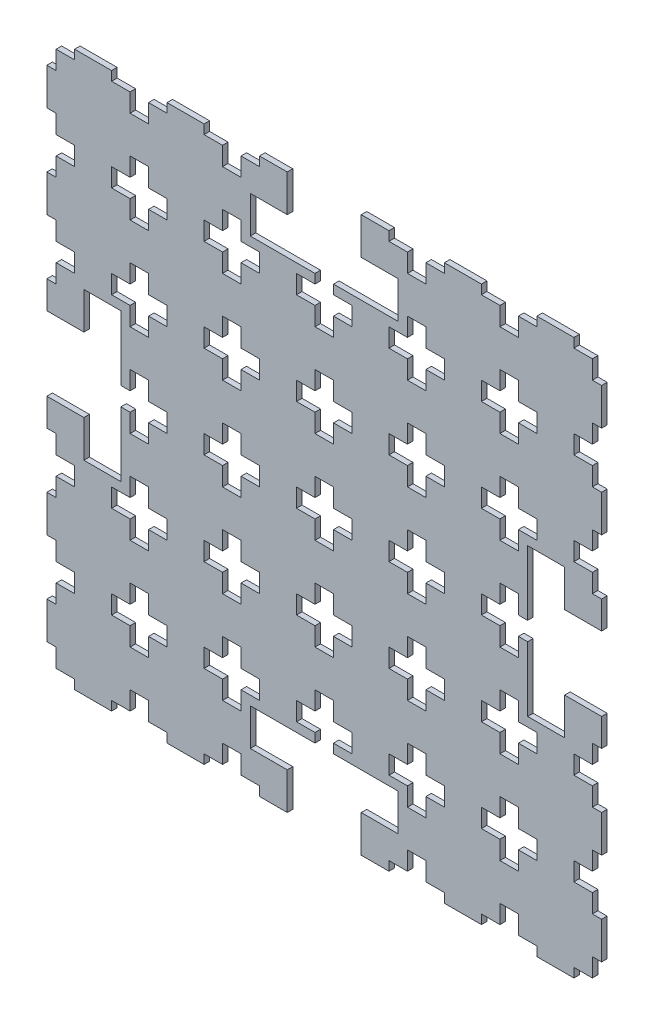
from build123d import *

# Parameters (mm, degrees)
ESQUISSE1_W             = 300
ESQUISSE1_H             = 300
BOSS_EXTRU_1_DEPTH      = 3
ENL_V_MAT_EXTRU_4_DEPTH = 4
ENL_V_MAT_EXTRU_5_DEPTH = 4


with BuildPart() as part:
    # Esquisse1 → Boss.-Extru.1 (new body)
    with BuildSketch(Plane.XY):
        with Locations((-68.640329964, 23.061811309)):
            Rectangle(ESQUISSE1_W, ESQUISSE1_H)
    extrude(amount=BOSS_EXTRU_1_DEPTH)

    # Esquisse4 → Enlèv. mat.-Extru.4 (cut, through all)
    with BuildSketch(Plane.XY.offset(3)):
        Polygon((81.359670036, 3.061811309), (81.359670036, 43.061811309), (61.359670036, 43.061811309), (61.359670036, 63.061811309), (41.359670036, 63.061811309), (41.359670036, -16.938188691), (61.359670036, -16.938188691), (61.359670036, 3.061811309), align=None)
        Polygon((-218.640329964, 43.061811309), (-218.640329964, 3.061811309), (-198.640329964, 3.061811309), (-198.640329964, -16.938188691), (-178.640329964, -16.938188691), (-178.640329964, 63.061811309), (-198.640329964, 63.061811309), (-198.640329964, 43.061811309), align=None)
        Polygon((-88.640329964, 173.061811309), (-88.640329964, 153.061811309), (-108.640329964, 153.061811309), (-108.640329964, 133.061811309), (-28.640329964, 133.061811309), (-28.640329964, 153.061811309), (-48.640329964, 153.061811309), (-48.640329964, 173.061811309), align=None)
        Polygon((-88.640329964, -126.938188691), (-88.640329964, -106.938188691), (-108.640329964, -106.938188691), (-108.640329964, -86.938188691), (-28.640329964, -86.938188691), (-28.640329964, -106.938188691), (-48.640329964, -106.938188691), (-48.640329964, -126.938188691), align=None)
    extrude(amount=-ENL_V_MAT_EXTRU_4_DEPTH, mode=Mode.SUBTRACT)

    # Esquisse2 → Enlèv. mat.-Extru.5 (cut, through all)
    with BuildSketch(Plane(origin=(0, 0, 0), x_dir=(-1, 0, 0), z_dir=(0, 0, -1))):
        Polygon((-81.359670036, 138.061811309), (-76.359670036, 138.061811309), (-76.359670036, 128.061811309), (-66.359670036, 128.061811309), (-66.359670036, 118.061811309), (-76.359670036, 118.061811309), (-76.359670036, 108.061811309), (-81.359670036, 108.061811309), align=None)
        Polygon((183.640329964, 173.061811309), (183.640329964, 168.061811309), (173.640329964, 168.061811309), (173.640329964, 158.061811309), (163.640329964, 158.061811309), (163.640329964, 168.061811309), (153.640329964, 168.061811309), (153.640329964, 173.061811309), align=None)
        Polygon((13.640329964, 128.061811309), (13.640329964, 138.061811309), (23.640329964, 138.061811309), (23.640329964, 128.061811309), (33.640329964, 128.061811309), (33.640329964, 118.061811309), (23.640329964, 118.061811309), (23.640329964, 108.061811309), (13.640329964, 108.061811309), (13.640329964, 118.061811309), (3.640329964, 118.061811309), (3.640329964, 128.061811309), align=None)
        Polygon((-81.359670036, 88.061811309), (-76.359670036, 88.061811309), (-76.359670036, 78.061811309), (-66.359670036, 78.061811309), (-66.359670036, 68.061811309), (-76.359670036, 68.061811309), (-76.359670036, 58.061811309), (-81.359670036, 58.061811309), align=None)
        Polygon((-81.359670036, 38.061811309), (-76.359670036, 38.061811309), (-76.359670036, 28.061811309), (-66.359670036, 28.061811309), (-66.359670036, 18.061811309), (-76.359670036, 18.061811309), (-76.359670036, 8.061811309), (-81.359670036, 8.061811309), align=None)
        Polygon((-81.359670036, -11.938188691), (-76.359670036, -11.938188691), (-76.359670036, -21.938188691), (-66.359670036, -21.938188691), (-66.359670036, -31.938188691), (-76.359670036, -31.938188691), (-76.359670036, -41.938188691), (-81.359670036, -41.938188691), align=None)
        Polygon((-81.359670036, -61.938188691), (-76.359670036, -61.938188691), (-76.359670036, -71.938188691), (-66.359670036, -71.938188691), (-66.359670036, -81.938188691), (-76.359670036, -81.938188691), (-76.359670036, -91.938188691), (-81.359670036, -91.938188691), align=None)
        Polygon((-81.359670036, -111.938188691), (-76.359670036, -111.938188691), (-76.359670036, -121.938188691), (-66.359670036, -121.938188691), (-66.359670036, -126.938188691), (-81.359670036, -126.938188691), align=None)
        Polygon((133.640329964, 173.061811309), (133.640329964, 168.061811309), (123.640329964, 168.061811309), (123.640329964, 158.061811309), (113.640329964, 158.061811309), (113.640329964, 168.061811309), (103.640329964, 168.061811309), (103.640329964, 173.061811309), align=None)
        Polygon((-36.359670036, 128.061811309), (-36.359670036, 138.061811309), (-26.359670036, 138.061811309), (-26.359670036, 128.061811309), (-16.359670036, 128.061811309), (-16.359670036, 118.061811309), (-26.359670036, 118.061811309), (-26.359670036, 108.061811309), (-36.359670036, 108.061811309), (-36.359670036, 118.061811309), (-46.359670036, 118.061811309), (-46.359670036, 128.061811309), align=None)
        Polygon((63.640329964, 128.061811309), (63.640329964, 138.061811309), (73.640329964, 138.061811309), (73.640329964, 128.061811309), (83.640329964, 128.061811309), (83.640329964, 118.061811309), (73.640329964, 118.061811309), (73.640329964, 108.061811309), (63.640329964, 108.061811309), (63.640329964, 118.061811309), (53.640329964, 118.061811309), (53.640329964, 128.061811309), align=None)
        Polygon((113.640329964, 128.061811309), (113.640329964, 138.061811309), (123.640329964, 138.061811309), (123.640329964, 128.061811309), (133.640329964, 128.061811309), (133.640329964, 118.061811309), (123.640329964, 118.061811309), (123.640329964, 108.061811309), (113.640329964, 108.061811309), (113.640329964, 118.061811309), (103.640329964, 118.061811309), (103.640329964, 128.061811309), align=None)
        Polygon((163.640329964, 128.061811309), (163.640329964, 138.061811309), (173.640329964, 138.061811309), (173.640329964, 128.061811309), (183.640329964, 128.061811309), (183.640329964, 118.061811309), (173.640329964, 118.061811309), (173.640329964, 108.061811309), (163.640329964, 108.061811309), (163.640329964, 118.061811309), (153.640329964, 118.061811309), (153.640329964, 128.061811309), align=None)
        Polygon((213.640329964, 128.061811309), (213.640329964, 138.061811309), (223.640329964, 138.061811309), (223.640329964, 128.061811309), (233.640329964, 128.061811309), (233.640329964, 118.061811309), (223.640329964, 118.061811309), (223.640329964, 108.061811309), (213.640329964, 108.061811309), (213.640329964, 118.061811309), (203.640329964, 118.061811309), (203.640329964, 128.061811309), align=None)
        Polygon((83.640329964, 173.061811309), (83.640329964, 168.061811309), (73.640329964, 168.061811309), (73.640329964, 158.061811309), (63.640329964, 158.061811309), (63.640329964, 168.061811309), (53.640329964, 168.061811309), (53.640329964, 173.061811309), align=None)
        Polygon((33.640329964, 173.061811309), (33.640329964, 168.061811309), (23.640329964, 168.061811309), (23.640329964, 158.061811309), (13.640329964, 158.061811309), (13.640329964, 168.061811309), (3.640329964, 168.061811309), (3.640329964, 173.061811309), align=None)
        Polygon((-16.359670036, 173.061811309), (-16.359670036, 168.061811309), (-26.359670036, 168.061811309), (-26.359670036, 158.061811309), (-36.359670036, 158.061811309), (-36.359670036, 168.061811309), (-46.359670036, 168.061811309), (-46.359670036, 173.061811309), align=None)
        Polygon((13.640329964, 78.061811309), (13.640329964, 88.061811309), (23.640329964, 88.061811309), (23.640329964, 78.061811309), (33.640329964, 78.061811309), (33.640329964, 68.061811309), (23.640329964, 68.061811309), (23.640329964, 58.061811309), (13.640329964, 58.061811309), (13.640329964, 68.061811309), (3.640329964, 68.061811309), (3.640329964, 78.061811309), align=None)
        Polygon((63.640329964, 78.061811309), (63.640329964, 88.061811309), (73.640329964, 88.061811309), (73.640329964, 78.061811309), (83.640329964, 78.061811309), (83.640329964, 68.061811309), (73.640329964, 68.061811309), (73.640329964, 58.061811309), (63.640329964, 58.061811309), (63.640329964, 68.061811309), (53.640329964, 68.061811309), (53.640329964, 78.061811309), align=None)
        Polygon((113.640329964, 78.061811309), (113.640329964, 88.061811309), (123.640329964, 88.061811309), (123.640329964, 78.061811309), (133.640329964, 78.061811309), (133.640329964, 68.061811309), (123.640329964, 68.061811309), (123.640329964, 58.061811309), (113.640329964, 58.061811309), (113.640329964, 68.061811309), (103.640329964, 68.061811309), (103.640329964, 78.061811309), align=None)
        Polygon((163.640329964, 78.061811309), (163.640329964, 88.061811309), (173.640329964, 88.061811309), (173.640329964, 78.061811309), (183.640329964, 78.061811309), (183.640329964, 68.061811309), (173.640329964, 68.061811309), (173.640329964, 58.061811309), (163.640329964, 58.061811309), (163.640329964, 68.061811309), (153.640329964, 68.061811309), (153.640329964, 78.061811309), align=None)
        Polygon((213.640329964, 78.061811309), (213.640329964, 88.061811309), (223.640329964, 88.061811309), (223.640329964, 78.061811309), (233.640329964, 78.061811309), (233.640329964, 68.061811309), (223.640329964, 68.061811309), (223.640329964, 58.061811309), (213.640329964, 58.061811309), (213.640329964, 68.061811309), (203.640329964, 68.061811309), (203.640329964, 78.061811309), align=None)
        Polygon((13.640329964, 28.061811309), (13.640329964, 38.061811309), (23.640329964, 38.061811309), (23.640329964, 28.061811309), (33.640329964, 28.061811309), (33.640329964, 18.061811309), (23.640329964, 18.061811309), (23.640329964, 8.061811309), (13.640329964, 8.061811309), (13.640329964, 18.061811309), (3.640329964, 18.061811309), (3.640329964, 28.061811309), align=None)
        Polygon((63.640329964, 28.061811309), (63.640329964, 38.061811309), (73.640329964, 38.061811309), (73.640329964, 28.061811309), (83.640329964, 28.061811309), (83.640329964, 18.061811309), (73.640329964, 18.061811309), (73.640329964, 8.061811309), (63.640329964, 8.061811309), (63.640329964, 18.061811309), (53.640329964, 18.061811309), (53.640329964, 28.061811309), align=None)
        Polygon((113.640329964, 28.061811309), (113.640329964, 38.061811309), (123.640329964, 38.061811309), (123.640329964, 28.061811309), (133.640329964, 28.061811309), (133.640329964, 18.061811309), (123.640329964, 18.061811309), (123.640329964, 8.061811309), (113.640329964, 8.061811309), (113.640329964, 18.061811309), (103.640329964, 18.061811309), (103.640329964, 28.061811309), align=None)
        Polygon((163.640329964, 28.061811309), (163.640329964, 38.061811309), (173.640329964, 38.061811309), (173.640329964, 28.061811309), (183.640329964, 28.061811309), (183.640329964, 18.061811309), (173.640329964, 18.061811309), (173.640329964, 8.061811309), (163.640329964, 8.061811309), (163.640329964, 18.061811309), (153.640329964, 18.061811309), (153.640329964, 28.061811309), align=None)
        Polygon((213.640329964, 28.061811309), (213.640329964, 38.061811309), (223.640329964, 38.061811309), (223.640329964, 28.061811309), (233.640329964, 28.061811309), (233.640329964, 18.061811309), (223.640329964, 18.061811309), (223.640329964, 8.061811309), (213.640329964, 8.061811309), (213.640329964, 18.061811309), (203.640329964, 18.061811309), (203.640329964, 28.061811309), align=None)
        Polygon((-66.359670036, 173.061811309), (-66.359670036, 168.061811309), (-76.359670036, 168.061811309), (-76.359670036, 158.061811309), (-81.359670036, 158.061811309), (-81.359670036, 173.061811309), align=None)
        Polygon((218.640329964, 158.061811309), (213.640329964, 158.061811309), (213.640329964, 168.061811309), (203.640329964, 168.061811309), (203.640329964, 173.061811309), (218.640329964, 173.061811309), align=None)
        Polygon((13.640329964, -21.938188691), (13.640329964, -11.938188691), (23.640329964, -11.938188691), (23.640329964, -21.938188691), (33.640329964, -21.938188691), (33.640329964, -31.938188691), (23.640329964, -31.938188691), (23.640329964, -41.938188691), (13.640329964, -41.938188691), (13.640329964, -31.938188691), (3.640329964, -31.938188691), (3.640329964, -21.938188691), align=None)
        Polygon((63.640329964, -21.938188691), (63.640329964, -11.938188691), (73.640329964, -11.938188691), (73.640329964, -21.938188691), (83.640329964, -21.938188691), (83.640329964, -31.938188691), (73.640329964, -31.938188691), (73.640329964, -41.938188691), (63.640329964, -41.938188691), (63.640329964, -31.938188691), (53.640329964, -31.938188691), (53.640329964, -21.938188691), align=None)
        Polygon((113.640329964, -21.938188691), (113.640329964, -11.938188691), (123.640329964, -11.938188691), (123.640329964, -21.938188691), (133.640329964, -21.938188691), (133.640329964, -31.938188691), (123.640329964, -31.938188691), (123.640329964, -41.938188691), (113.640329964, -41.938188691), (113.640329964, -31.938188691), (103.640329964, -31.938188691), (103.640329964, -21.938188691), align=None)
        Polygon((163.640329964, -21.938188691), (163.640329964, -11.938188691), (173.640329964, -11.938188691), (173.640329964, -21.938188691), (183.640329964, -21.938188691), (183.640329964, -31.938188691), (173.640329964, -31.938188691), (173.640329964, -41.938188691), (163.640329964, -41.938188691), (163.640329964, -31.938188691), (153.640329964, -31.938188691), (153.640329964, -21.938188691), align=None)
        Polygon((213.640329964, -21.938188691), (213.640329964, -11.938188691), (223.640329964, -11.938188691), (223.640329964, -21.938188691), (233.640329964, -21.938188691), (233.640329964, -31.938188691), (223.640329964, -31.938188691), (223.640329964, -41.938188691), (213.640329964, -41.938188691), (213.640329964, -31.938188691), (203.640329964, -31.938188691), (203.640329964, -21.938188691), align=None)
        Polygon((13.640329964, -71.938188691), (13.640329964, -61.938188691), (23.640329964, -61.938188691), (23.640329964, -71.938188691), (33.640329964, -71.938188691), (33.640329964, -81.938188691), (23.640329964, -81.938188691), (23.640329964, -91.938188691), (13.640329964, -91.938188691), (13.640329964, -81.938188691), (3.640329964, -81.938188691), (3.640329964, -71.938188691), align=None)
        Polygon((63.640329964, -71.938188691), (63.640329964, -61.938188691), (73.640329964, -61.938188691), (73.640329964, -71.938188691), (83.640329964, -71.938188691), (83.640329964, -81.938188691), (73.640329964, -81.938188691), (73.640329964, -91.938188691), (63.640329964, -91.938188691), (63.640329964, -81.938188691), (53.640329964, -81.938188691), (53.640329964, -71.938188691), align=None)
        Polygon((113.640329964, -71.938188691), (113.640329964, -61.938188691), (123.640329964, -61.938188691), (123.640329964, -71.938188691), (133.640329964, -71.938188691), (133.640329964, -81.938188691), (123.640329964, -81.938188691), (123.640329964, -91.938188691), (113.640329964, -91.938188691), (113.640329964, -81.938188691), (103.640329964, -81.938188691), (103.640329964, -71.938188691), align=None)
        Polygon((163.640329964, -71.938188691), (163.640329964, -61.938188691), (173.640329964, -61.938188691), (173.640329964, -71.938188691), (183.640329964, -71.938188691), (183.640329964, -81.938188691), (173.640329964, -81.938188691), (173.640329964, -91.938188691), (163.640329964, -91.938188691), (163.640329964, -81.938188691), (153.640329964, -81.938188691), (153.640329964, -71.938188691), align=None)
        Polygon((213.640329964, -71.938188691), (213.640329964, -61.938188691), (223.640329964, -61.938188691), (223.640329964, -71.938188691), (233.640329964, -71.938188691), (233.640329964, -81.938188691), (223.640329964, -81.938188691), (223.640329964, -91.938188691), (213.640329964, -91.938188691), (213.640329964, -81.938188691), (203.640329964, -81.938188691), (203.640329964, -71.938188691), align=None)
        Polygon((13.640329964, -121.938188691), (13.640329964, -111.938188691), (23.640329964, -111.938188691), (23.640329964, -121.938188691), (33.640329964, -121.938188691), (33.640329964, -131.938188691), (23.640329964, -131.938188691), (23.640329964, -141.938188691), (13.640329964, -141.938188691), (13.640329964, -131.938188691), (3.640329964, -131.938188691), (3.640329964, -121.938188691), align=None)
        Polygon((63.640329964, -121.938188691), (63.640329964, -111.938188691), (73.640329964, -111.938188691), (73.640329964, -121.938188691), (83.640329964, -121.938188691), (83.640329964, -131.938188691), (73.640329964, -131.938188691), (73.640329964, -141.938188691), (63.640329964, -141.938188691), (63.640329964, -131.938188691), (53.640329964, -131.938188691), (53.640329964, -121.938188691), align=None)
        Polygon((113.640329964, -121.938188691), (113.640329964, -111.938188691), (123.640329964, -111.938188691), (123.640329964, -121.938188691), (133.640329964, -121.938188691), (133.640329964, -131.938188691), (123.640329964, -131.938188691), (123.640329964, -141.938188691), (113.640329964, -141.938188691), (113.640329964, -131.938188691), (103.640329964, -131.938188691), (103.640329964, -121.938188691), align=None)
        Polygon((163.640329964, -121.938188691), (163.640329964, -111.938188691), (173.640329964, -111.938188691), (173.640329964, -121.938188691), (183.640329964, -121.938188691), (183.640329964, -131.938188691), (173.640329964, -131.938188691), (173.640329964, -141.938188691), (163.640329964, -141.938188691), (163.640329964, -131.938188691), (153.640329964, -131.938188691), (153.640329964, -121.938188691), align=None)
        Polygon((213.640329964, -121.938188691), (213.640329964, -111.938188691), (223.640329964, -111.938188691), (223.640329964, -121.938188691), (233.640329964, -121.938188691), (233.640329964, -131.938188691), (223.640329964, -131.938188691), (223.640329964, -141.938188691), (213.640329964, -141.938188691), (213.640329964, -131.938188691), (203.640329964, -131.938188691), (203.640329964, -121.938188691), align=None)
        Polygon((13.640329964, -171.938188691), (13.640329964, -161.938188691), (23.640329964, -161.938188691), (23.640329964, -171.938188691), (33.640329964, -171.938188691), (33.640329964, -181.938188691), (23.640329964, -181.938188691), (23.640329964, -191.938188691), (13.640329964, -191.938188691), (13.640329964, -181.938188691), (3.640329964, -181.938188691), (3.640329964, -171.938188691), align=None)
        Polygon((63.640329964, -171.938188691), (63.640329964, -161.938188691), (73.640329964, -161.938188691), (73.640329964, -171.938188691), (83.640329964, -171.938188691), (83.640329964, -181.938188691), (73.640329964, -181.938188691), (73.640329964, -191.938188691), (63.640329964, -191.938188691), (63.640329964, -181.938188691), (53.640329964, -181.938188691), (53.640329964, -171.938188691), align=None)
        Polygon((113.640329964, -171.938188691), (113.640329964, -161.938188691), (123.640329964, -161.938188691), (123.640329964, -171.938188691), (133.640329964, -171.938188691), (133.640329964, -181.938188691), (123.640329964, -181.938188691), (123.640329964, -191.938188691), (113.640329964, -191.938188691), (113.640329964, -181.938188691), (103.640329964, -181.938188691), (103.640329964, -171.938188691), align=None)
        Polygon((63.640329964, -221.938188691), (63.640329964, -211.938188691), (73.640329964, -211.938188691), (73.640329964, -221.938188691), (83.640329964, -221.938188691), (83.640329964, -231.938188691), (73.640329964, -231.938188691), (73.640329964, -241.938188691), (63.640329964, -241.938188691), (63.640329964, -231.938188691), (53.640329964, -231.938188691), (53.640329964, -221.938188691), align=None)
        Polygon((-36.359670036, 78.061811309), (-36.359670036, 88.061811309), (-26.359670036, 88.061811309), (-26.359670036, 78.061811309), (-16.359670036, 78.061811309), (-16.359670036, 68.061811309), (-26.359670036, 68.061811309), (-26.359670036, 58.061811309), (-36.359670036, 58.061811309), (-36.359670036, 68.061811309), (-46.359670036, 68.061811309), (-46.359670036, 78.061811309), align=None)
        Polygon((-36.359670036, 28.061811309), (-36.359670036, 38.061811309), (-26.359670036, 38.061811309), (-26.359670036, 28.061811309), (-16.359670036, 28.061811309), (-16.359670036, 18.061811309), (-26.359670036, 18.061811309), (-26.359670036, 8.061811309), (-36.359670036, 8.061811309), (-36.359670036, 18.061811309), (-46.359670036, 18.061811309), (-46.359670036, 28.061811309), align=None)
        Polygon((-36.359670036, -21.938188691), (-36.359670036, -11.938188691), (-26.359670036, -11.938188691), (-26.359670036, -21.938188691), (-16.359670036, -21.938188691), (-16.359670036, -31.938188691), (-26.359670036, -31.938188691), (-26.359670036, -41.938188691), (-36.359670036, -41.938188691), (-36.359670036, -31.938188691), (-46.359670036, -31.938188691), (-46.359670036, -21.938188691), align=None)
        Polygon((-36.359670036, -71.938188691), (-36.359670036, -61.938188691), (-26.359670036, -61.938188691), (-26.359670036, -71.938188691), (-16.359670036, -71.938188691), (-16.359670036, -81.938188691), (-26.359670036, -81.938188691), (-26.359670036, -91.938188691), (-36.359670036, -91.938188691), (-36.359670036, -81.938188691), (-46.359670036, -81.938188691), (-46.359670036, -71.938188691), align=None)
        Polygon((-36.359670036, -121.938188691), (-36.359670036, -111.938188691), (-26.359670036, -111.938188691), (-26.359670036, -121.938188691), (-16.359670036, -121.938188691), (-16.359670036, -131.938188691), (-26.359670036, -131.938188691), (-26.359670036, -141.938188691), (-36.359670036, -141.938188691), (-36.359670036, -131.938188691), (-46.359670036, -131.938188691), (-46.359670036, -121.938188691), align=None)
    extrude(amount=-ENL_V_MAT_EXTRU_5_DEPTH, mode=Mode.SUBTRACT)


solid = part.part
